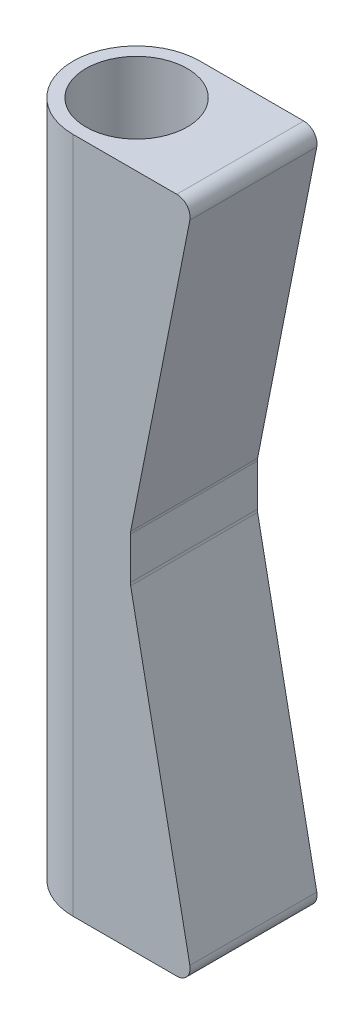
from build123d import *

# Parameters (mm, degrees)
SKETCH1_R           = 14.2875
SKETCH1_R_2         = 11.4125
BOSS_EXTRUDE1_DEPTH = 152.4
SKETCH2_W           = 28.575
SKETCH2_H           = 152.4
BOSS_EXTRUDE2_DEPTH = 12.7
BOSS_EXTRUDE3_DEPTH = 152.4
CUT_EXTRUDE1_DEPTH  = 29.575
FILLET1_R           = 3


with BuildPart() as part:
    # Sketch1 → Boss-Extrude1 (new body)
    with BuildSketch(Plane(origin=(0, 0, 0), x_dir=(1, 0, 0), z_dir=(0, 1, 0))):
        Circle(SKETCH1_R)
        Circle(SKETCH1_R_2, mode=Mode.SUBTRACT)
    extrude(amount=BOSS_EXTRUDE1_DEPTH)



with BuildPart() as body_2:
    # Sketch2 → Boss-Extrude2 (new body)
    with BuildSketch(Plane(origin=(14.2875, 0, 0), x_dir=(0, 0, -1), z_dir=(1, 0, 0))):
        with Locations((0, 76.2)):
            Rectangle(SKETCH2_W, SKETCH2_H)
    extrude(amount=BOSS_EXTRUDE2_DEPTH)


with BuildPart() as part_1:
    add(part.part)

    add(body_2.part)  # Boss-Extrude3 merges body 2
    # Sketch3 → Boss-Extrude3 (add, through all)
    with BuildSketch(Plane(origin=(0, 152.4, 0), x_dir=(1, 0, 0), z_dir=(0, 1, 0))):
        with BuildLine():
            Line((14.2875, -14.2875), (0, -14.2875))
            ThreePointArc((0, -14.2875), (14.2875, 0), (0, 14.2875))
            Line((0, 14.2875), (14.2875, 14.2875))
            Line((14.2875, 14.2875), (26.9875, 14.2875))
            Line((26.9875, 14.2875), (26.9875, -14.2875))
            Line((26.9875, -14.2875), (14.2875, -14.2875))
        make_face()
    extrude(amount=-BOSS_EXTRUDE3_DEPTH)

    # Sketch5 → Cut-Extrude1 (cut, through all)
    with BuildSketch(Plane.XY.offset(14.2875)):
        Polygon((26.9875, 0), (12.897222949, 71.2), (12.897222949, 81.2), (26.9875, 152.4), align=None)
    extrude(amount=-CUT_EXTRUDE1_DEPTH, mode=Mode.SUBTRACT)

    # Fillet1
    fillet1_edges = [part_1.edges().sort_by_distance(p)[0] for p in [
        (26.9875, 0, 0),
        (26.9875, 152.4, 0),
        (12.897222949, 71.2, 0),
        (12.897222949, 81.2, 0),
    ]]
    fillet(fillet1_edges, radius=FILLET1_R)


solid = part_1.part
